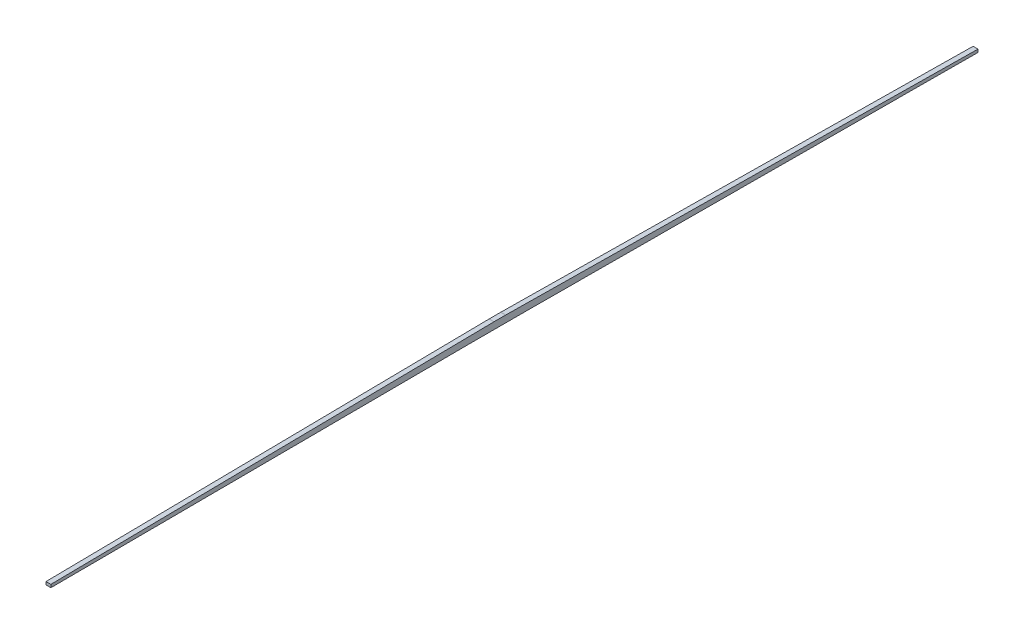
from build123d import *

# Parameters (mm, degrees)
EXTRUDE1_DEPTH = 5


with BuildPart() as part:
    # Sketch1 → Extrude1 (new body)
    with BuildSketch(Plane(origin=(0, 0, 0), x_dir=(0, 0, -1), z_dir=(1, 0, 0))):
        Polygon((6, 0), (490, -6), (490, -9), (30, -7), (-30, -7), (-460, -9), (-460, -6), (-6, 0), align=None)
    extrude(amount=EXTRUDE1_DEPTH)


solid = part.part
